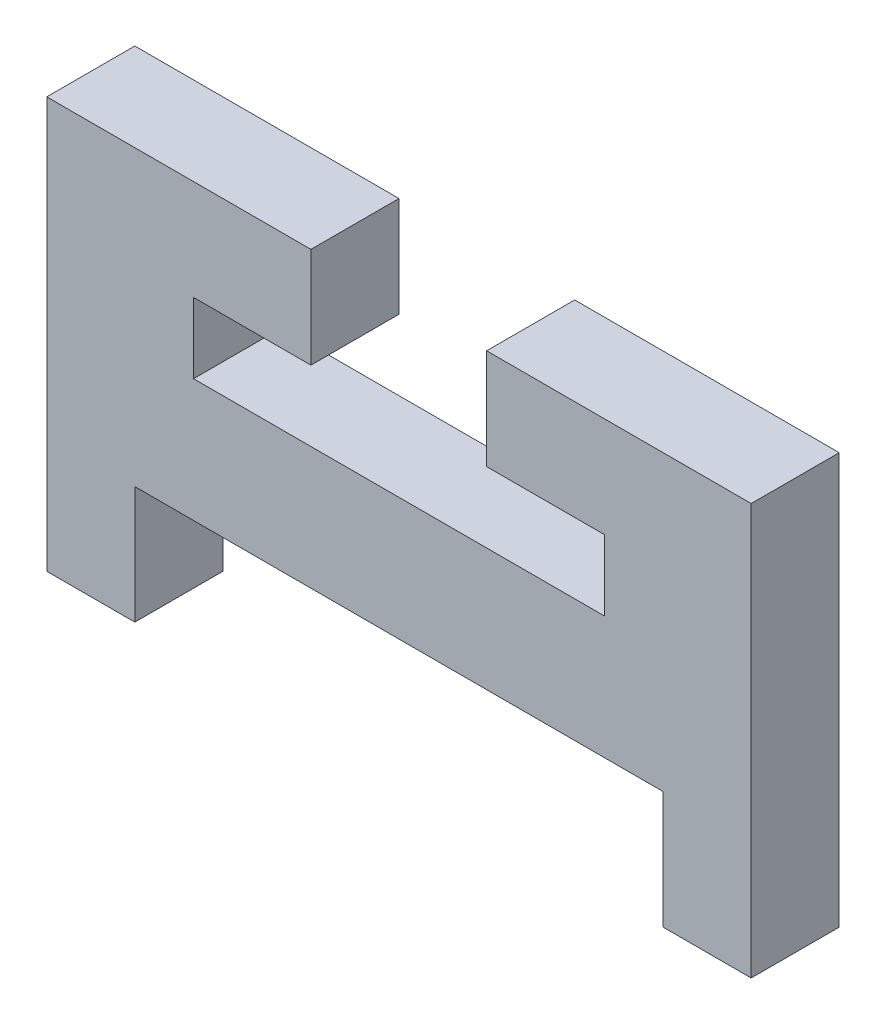
from build123d import *

# Parameters (mm, degrees)
SALIENTE_EXTRUIR1_DEPTH = 3


with BuildPart() as part:
    # Model → Saliente-Extruir1 (new body)
    with BuildSketch(Plane.XY):
        Polygon((32.4, 16.302683294), (25.9, 16.302683294), (25.9, 18.702683294), (29.9, 18.702683294), (29.9, 22.12), (20.9, 22.12), (20.9, 8.12), (23.9, 8.12), (23.9, 12.12), (41.9, 12.12), (41.9, 8.12), (44.9, 8.12), (44.9, 22.12), (35.886385402, 22.12), (35.886385402, 18.702683294), (39.9, 18.702683294), (39.9, 16.302683294), (33.4, 16.302683294), align=None)
    extrude(amount=SALIENTE_EXTRUIR1_DEPTH)


solid = part.part
